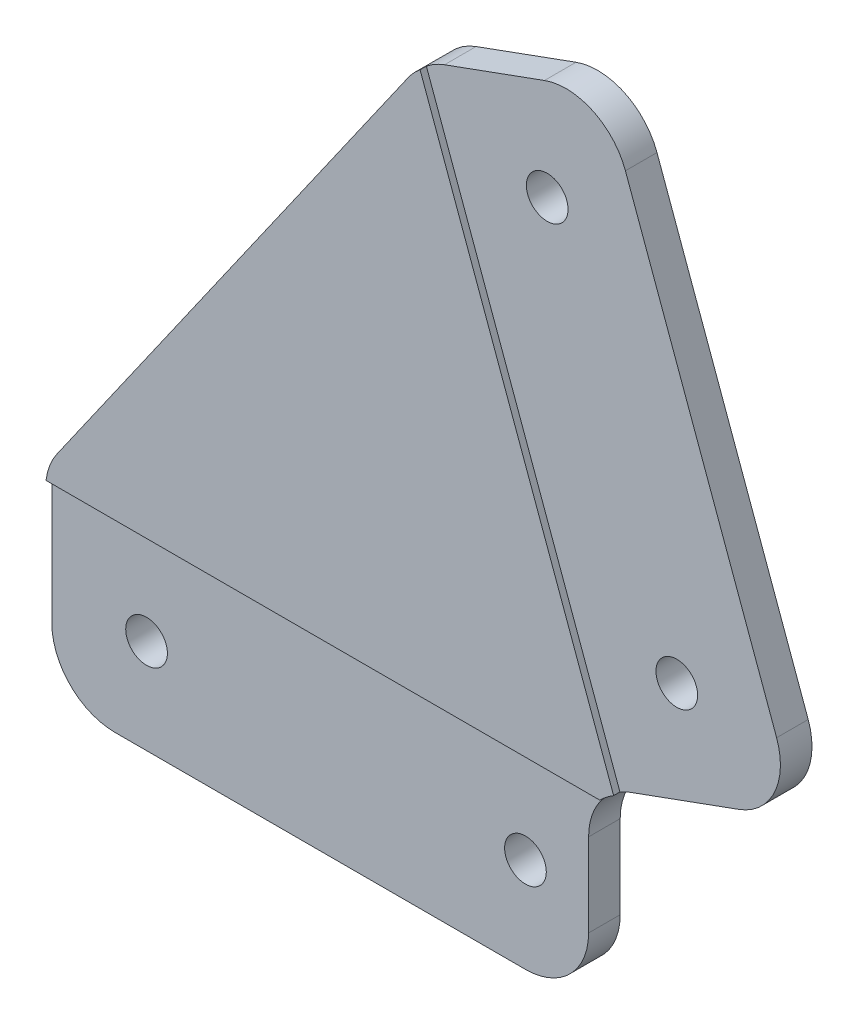
from build123d import *

# Parameters (mm, degrees)
EXTRUDE_1_DEPTH     = 3
SKETCH_2_R          = 1.65
CUT_EXTRUDE_1_DEPTH = 3
FILLET_1_R          = 5
SKETCH_4_W          = 44.5
SKETCH_4_H          = 15.05
CUT_EXTRUDE_2_DEPTH = 0.5


with BuildPart() as part:
    # ｽｹｯﾁ1 → ﾎﾞｽ - 押し出し1 (new body)
    with BuildSketch(Plane.XY):
        Polygon((437.5, -0.909925586), (454.095389312, 5.13030215), (438.704482862, 47.416470085), (424.60909355, 42.286167935), (395, 0), (395, -16), (437.5, -16), align=None)
    extrude(amount=EXTRUDE_1_DEPTH)

    # ｽｹｯﾁ2 → ｶｯﾄ - 押し出し1 (cut)
    with BuildSketch(Plane.XY.offset(3)):
        with Locations((402.5, -8.5)):
            Circle(SKETCH_2_R)
        with Locations((432.5, -8.5)):
            Circle(SKETCH_2_R)
        with Locations((434.221939281, 37.803624354)):
            Circle(SKETCH_2_R)
        with Locations((444.482543581, 9.612845731)):
            Circle(SKETCH_2_R)
    extrude(amount=-CUT_EXTRUDE_1_DEPTH, mode=Mode.SUBTRACT)

    # ﾌｨﾚｯﾄ1
    fillet_1_edges = [part.edges().sort_by_distance(p)[0] for p in [
        (437.5, -16, 1.5),
        (395, -16, 1.5),
        (395, 0, 1.5),
        (424.60909355, 42.286167935, 1.5),
        (438.704482862, 47.416470085, 1.5),
        (454.095389312, 5.13030215, 1.5),
        (437.5, -0.909925586, 1.5),
    ]]
    fillet(fillet_1_edges, radius=FILLET_1_R)

    # ｽｹｯﾁ4 → ｶｯﾄ - 押し出し2 (cut)
    with BuildSketch(Plane.XY.offset(3)):
        Polygon((438.704482862, 47.416470085), (454.437409455, 4.190609529), (440.295035512, -0.956793628), (424.562108919, 42.269066928), align=None)
        with Locations((417.25, -8.475)):
            Rectangle(SKETCH_4_W, SKETCH_4_H)
    extrude(amount=-CUT_EXTRUDE_2_DEPTH, mode=Mode.SUBTRACT)


solid = part.part
